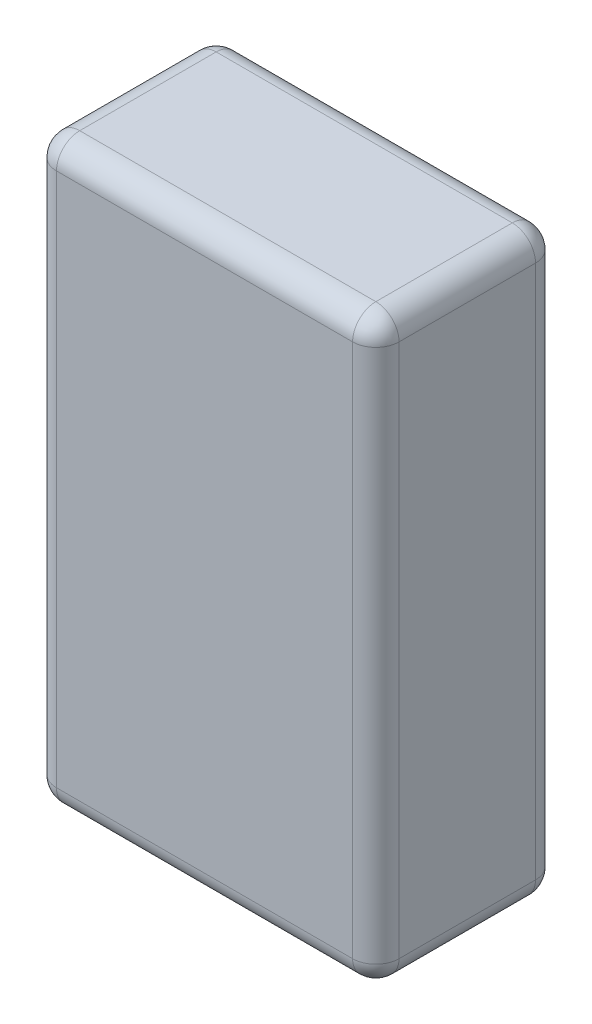
from build123d import *

# Parameters (mm, degrees)
SKETCH1_W           = 29.972
SKETCH1_H           = 16.002
BOSS_EXTRUDE1_DEPTH = 50.8
FILLET1_R           = 2.032


with BuildPart() as part:
    # Sketch1 → Boss-Extrude1 (new body)
    with BuildSketch(Plane(origin=(0, 0, 0), x_dir=(1, 0, 0), z_dir=(0, 1, 0))):
        with Locations((14.986, 8.001)):
            Rectangle(SKETCH1_W, SKETCH1_H)
    extrude(amount=BOSS_EXTRUDE1_DEPTH)

    # Fillet1
    fillet1_edges = [part.edges().sort_by_distance(p)[0] for p in [
        (29.972, 50.8, -8.001),
        (14.986, 50.8, -16.002),
        (0, 50.8, -8.001),
        (14.986, 0, -16.002),
        (29.972, 0, -8.001),
        (14.986, 0, 0),
        (0, 0, -8.001),
        (0, 25.4, -16.002),
        (29.972, 25.4, -16.002),
        (29.972, 25.4, 0),
        (0, 25.4, 0),
        (14.986, 50.8, 0),
    ]]
    fillet(fillet1_edges, radius=FILLET1_R)


solid = part.part
